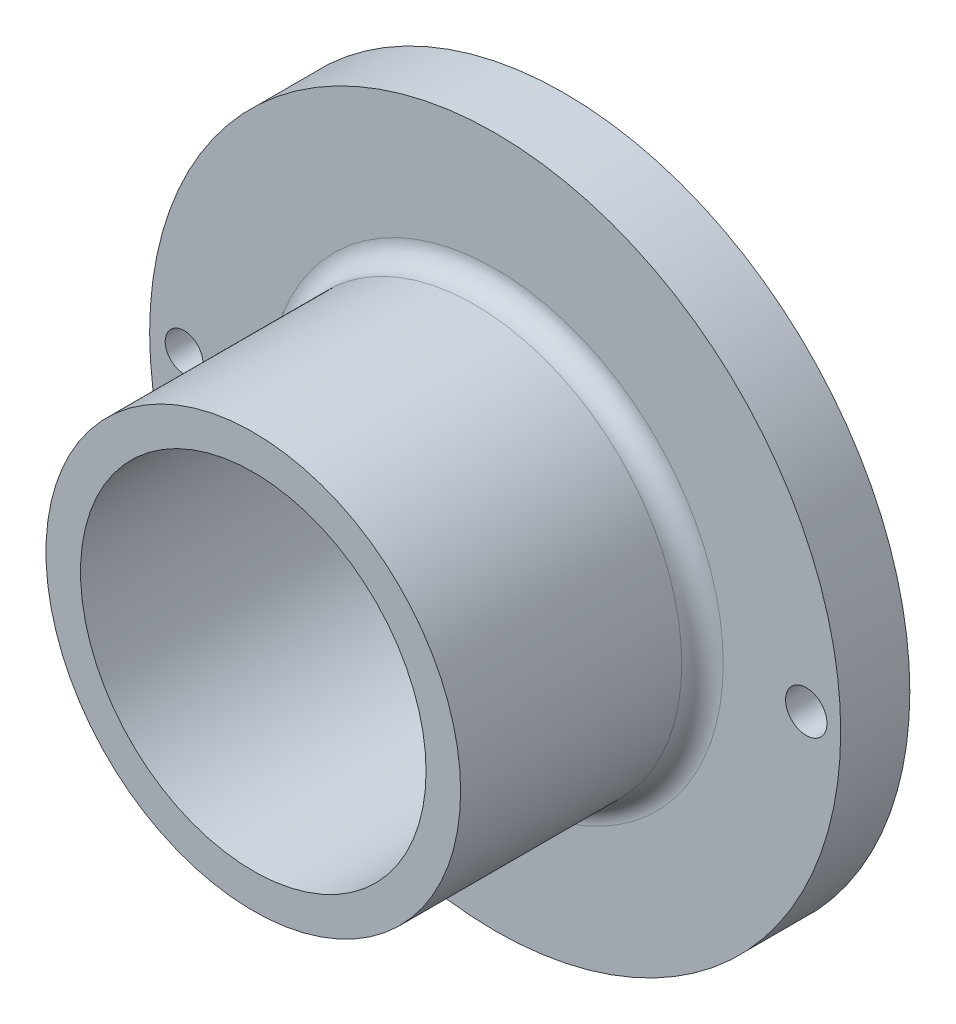
from build123d import *

# Parameters (mm, degrees)
SKETCH1_R           = 50
SKETCH1_R_2         = 25
BOSS_EXTRUDE1_DEPTH = 10
SKETCH2_R           = 30
SKETCH2_R_2         = 25
BOSS_EXTRUDE2_DEPTH = 45
FILLET1_R           = 3
SKETCH3_R           = 3
SKETCH3_R_2         = 2.728941423
CUT_EXTRUDE1_DEPTH  = 50


with BuildPart() as part:
    # Sketch1 → Boss-Extrude1 (new body)
    with BuildSketch(Plane.XY):
        Circle(SKETCH1_R)
        Circle(SKETCH1_R_2, mode=Mode.SUBTRACT)
    extrude(amount=BOSS_EXTRUDE1_DEPTH)

    # Sketch2 → Boss-Extrude2 (add)
    with BuildSketch(Plane.XY):
        Circle(SKETCH2_R)
        Circle(SKETCH2_R_2, mode=Mode.SUBTRACT)
    extrude(amount=BOSS_EXTRUDE2_DEPTH)

    # Fillet1
    fillet1_edges = [part.edges().sort_by_distance(p)[0] for p in [
        (-30, 0, 10),
    ]]
    fillet(fillet1_edges, radius=FILLET1_R)

    # Sketch3 → Cut-Extrude1 (cut)
    with BuildSketch(Plane.XY):
        with Locations((45.016491683, 0)):
            Circle(SKETCH3_R)
        with Locations((-45.016491683, 0)):
            Circle(SKETCH3_R_2)
    extrude(amount=CUT_EXTRUDE1_DEPTH, mode=Mode.SUBTRACT)


solid = part.part
